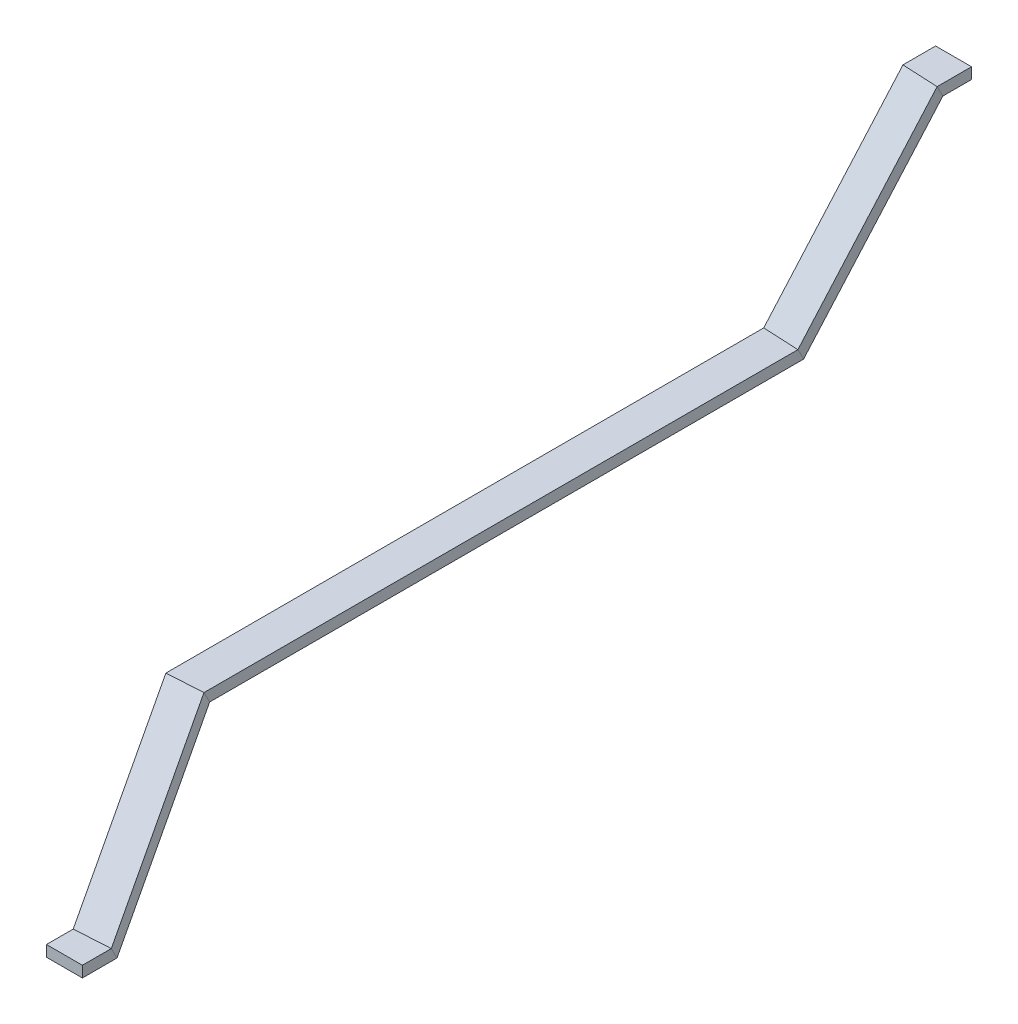
from build123d import *

# Parameters (mm, degrees)
SKETCH2_W = 70.25
SKETCH2_H = 21.6


with BuildPart() as part:
    # Sweep1: sweep along a curve in space
    with BuildLine() as sweep1_path:
        Line((3251.181818755, -307.327166096, 1441.624252092), (3251.181818755, -307.327166096, 1381.624252092))
        Line((3215.675, 0, 1165), (3251.181818755, -307.327166096, 1381.624252092))
        Line((3215.675, 0, 1165), (3215.675, 0, 0))
        Line((3215.675, 0, 0), (3247.785290657, 341.355989282, -240.075201436))
        Line((3247.785290657, 341.355989282, -240.075201436), (3247.785290657, 341.355989282, -300.075201436))
    # Sketch2 → Sweep1 (sweep)
    with BuildSketch(Plane(origin=(3247.785290657, 341.355989282, -300.075201436), x_dir=(1, 0, 0), z_dir=(0, 0, 1))):
        Rectangle(SKETCH2_W, SKETCH2_H)
    sweep(path=sweep1_path.line, transition=Transition.RIGHT)


solid = part.part
